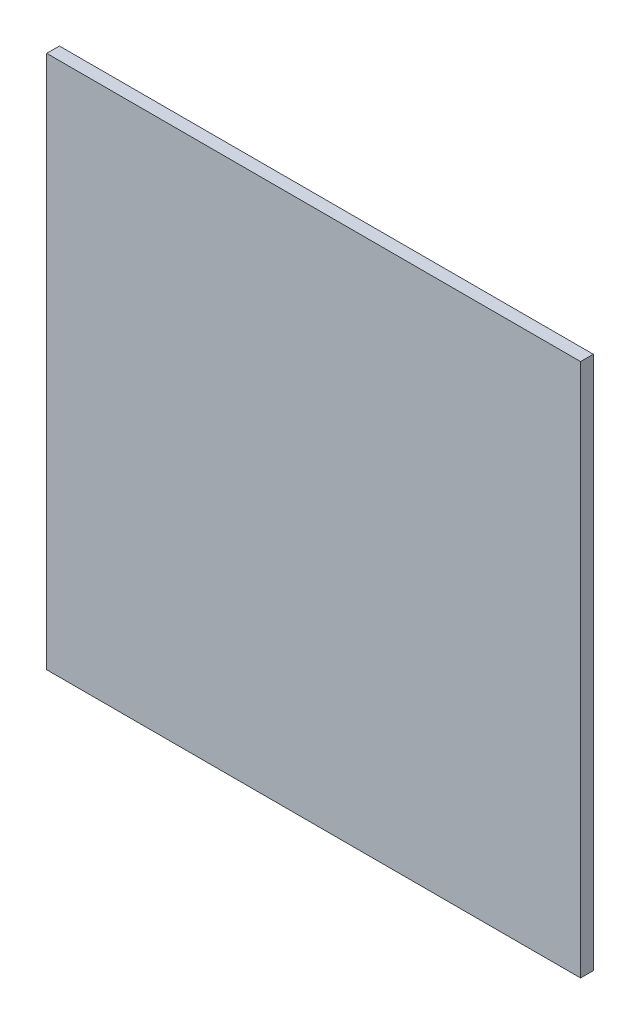
from build123d import *

# Parameters (mm, degrees)
SKETCH1_W           = 266.7
SKETCH1_H           = 266.7
BOSS_EXTRUDE1_DEPTH = 6.35


with BuildPart() as part:
    # Sketch1 → Boss-Extrude1 (new body)
    with BuildSketch(Plane.XY):
        Rectangle(SKETCH1_W, SKETCH1_H)
    extrude(amount=BOSS_EXTRUDE1_DEPTH)


solid = part.part
